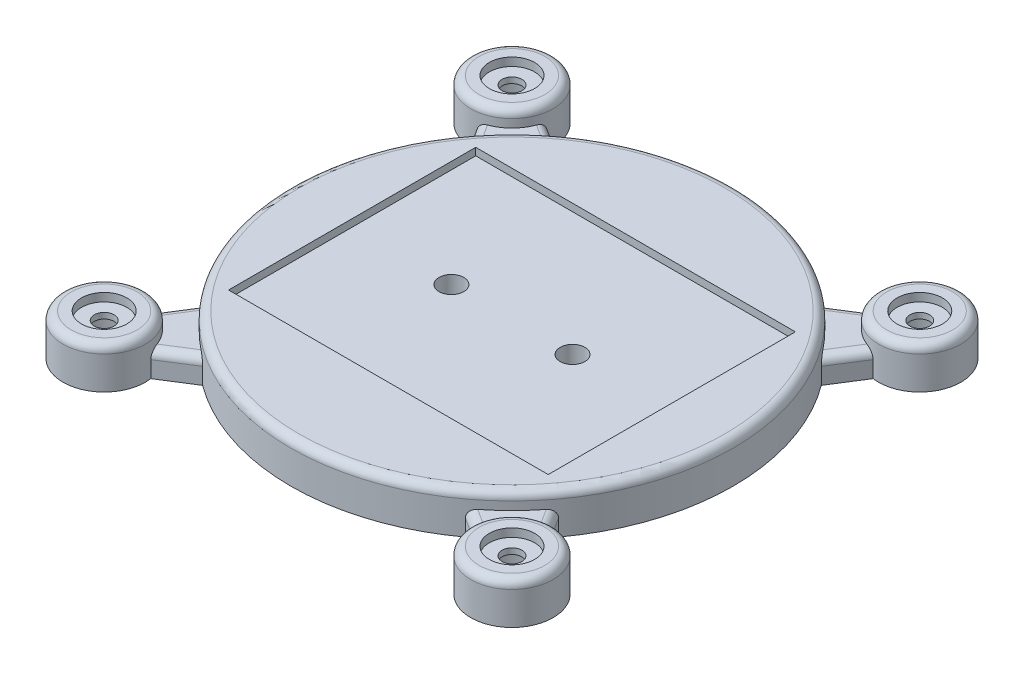
from build123d import *

# Parameters (mm, degrees)
SKETCH1_R                 = 26.85
BOSS_EXTRUDE1_DEPTH       = 5
FILLET1_R                 = 1
SKETCH2_W                 = 38.8
SKETCH2_H                 = 30
CUT_EXTRUDE1_DEPTH        = 0.9
SKETCH3_R                 = 1.5
CUT_EXTRUDE2_DEPTH        = 5.1
SKETCH5_R                 = 5
BOSS_EXTRUDE4_DEPTH       = 5
BOSS_EXTRUDE4_2_DEPTH     = 5
BOSS_EXTRUDE4_3_DEPTH     = 5
BOSS_EXTRUDE4_4_DEPTH     = 5
BOSS_EXTRUDE5_DEPTH       = 3
FILLET5_R                 = 1
CIRPATTERN20_COUNT        = 4
FILLET5_OF_CIRPATTERN20_R = 1
FILLET6_R                 = 1
FILLET7_R                 = 1
FILLET8_R                 = 1
FILLET9_R                 = 1
SKETCH9_R                 = 2.75
CUT_EXTRUDE5_DEPTH        = 1
SKETCH10_R                = 1.2
CUT_EXTRUDE6_DEPTH        = 5.0000001
SKETCH11_R                = 3.75
CUT_EXTRUDE7_DEPTH        = 3.3


with BuildPart() as part:
    # Sketch1 → Boss-Extrude1 (new body)
    with BuildSketch(Plane(origin=(0, 0, 0), x_dir=(1, 0, 0), z_dir=(0, 1, 0))):
        Circle(SKETCH1_R)
    extrude(amount=BOSS_EXTRUDE1_DEPTH)

    # Fillet1
    fillet1_edges = [part.edges().sort_by_distance(p)[0] for p in [
        (-26.85, 5, 0),
    ]]
    fillet(fillet1_edges, radius=FILLET1_R)

    # Sketch2 → Cut-Extrude1 (cut)
    with BuildSketch(Plane(origin=(0, 5, 0), x_dir=(1, 0, 0), z_dir=(0, 1, 0))):
        Rectangle(SKETCH2_W, SKETCH2_H)
    extrude(amount=-CUT_EXTRUDE1_DEPTH, mode=Mode.SUBTRACT)

    # Sketch3 → Cut-Extrude2 (cut, through all)
    with BuildSketch(Plane(origin=(0, 4.1, 0), x_dir=(1, 0, 0), z_dir=(0, 1, 0))):
        with Locations((7.35, 0)):
            Circle(SKETCH3_R)
        with Locations((-7.35, 0)):
            Circle(SKETCH3_R)
    extrude(amount=-CUT_EXTRUDE2_DEPTH, mode=Mode.SUBTRACT)



with BuildPart() as body_2:
    # Sketch5 → Boss-Extrude4 (new body)
    with BuildSketch(Plane(origin=(0, 0, 0), x_dir=(1, 0, 0), z_dir=(0, 1, 0))):
        with Locations((24.748737342, -24.748737342)):
            Circle(SKETCH5_R)
    extrude(amount=BOSS_EXTRUDE4_DEPTH)


with BuildPart() as body_3:
    # Sketch5 → Boss-Extrude4 2 (new body)
    with BuildSketch(Plane(origin=(0, 0, 0), x_dir=(1, 0, 0), z_dir=(0, 1, 0))):
        with Locations((-24.748737342, -24.748737342)):
            Circle(SKETCH5_R)
    extrude(amount=BOSS_EXTRUDE4_2_DEPTH)

    # Fillet8
    fillet8_edges = [body_3.edges().sort_by_distance(p)[0] for p in [
        (-29.748737342, 5, 24.748737342),
    ]]
    fillet(fillet8_edges, radius=FILLET8_R)


with BuildPart() as body_4:
    # Sketch5 → Boss-Extrude4 3 (new body)
    with BuildSketch(Plane(origin=(0, 0, 0), x_dir=(1, 0, 0), z_dir=(0, 1, 0))):
        with Locations((-24.748737342, 24.748737342)):
            Circle(SKETCH5_R)
    extrude(amount=BOSS_EXTRUDE4_3_DEPTH)

    # Fillet6
    fillet6_edges = [body_4.edges().sort_by_distance(p)[0] for p in [
        (-29.748737342, 5, -24.748737342),
    ]]
    fillet(fillet6_edges, radius=FILLET6_R)


with BuildPart() as body_5:
    # Sketch5 → Boss-Extrude4 4 (new body)
    with BuildSketch(Plane(origin=(0, 0, 0), x_dir=(1, 0, 0), z_dir=(0, 1, 0))):
        with Locations((24.748737342, 24.748737342)):
            Circle(SKETCH5_R)
    extrude(amount=BOSS_EXTRUDE4_4_DEPTH)

    # Fillet7
    fillet7_edges = [body_5.edges().sort_by_distance(p)[0] for p in [
        (19.748737342, 5, -24.748737342),
    ]]
    fillet(fillet7_edges, radius=FILLET7_R)


with BuildPart() as part_1:
    add(part.part)

    add(body_2.part)  # Boss-Extrude5 merges body 2
    # Sketch6 → Boss-Extrude5 (add)
    with BuildSketch(Plane(origin=(0, 0, 0), x_dir=(1, 0, 0), z_dir=(0, 1, 0))):
        with BuildLine():
            Line((24.04163056, -19.798989873), (21.602378494, -15.945524244))
            ThreePointArc((21.602378494, -15.945524244), (18.985817075, -18.985817075), (15.945524244, -21.602378494))
            Line((15.945524244, -21.602378494), (19.798989873, -24.04163056))
            ThreePointArc((19.798989873, -24.04163056), (21.213203436, -21.213203436), (24.04163056, -19.798989873))
        make_face()
    boss_extrude5 = extrude(amount=BOSS_EXTRUDE5_DEPTH)

    # Fillet5
    fillet5_edges = [part_1.edges().sort_by_distance(p)[0] for p in [
        (17.872257059, 3, 22.822004527),
        (22.822004527, 3, 17.872257059),
    ]]
    fillet(fillet5_edges, radius=FILLET5_R)

    # CirPattern20: Boss-Extrude5 ×4 about axis
    cirpattern20_axis = Axis((0, 0, 0), (0, 1, 0))
    for i in range(1, CIRPATTERN20_COUNT):
        add(boss_extrude5.rotate(cirpattern20_axis, i * 360 / CIRPATTERN20_COUNT))

    # Fillet5 of CirPattern20
    fillet5_of_cirpattern20_edges = [part_1.edges().sort_by_distance(p)[0] for p in [
        (22.822004527, 3, -17.872257059),
        (17.872257059, 3, -22.822004527),
        (-17.872257059, 3, -22.822004527),
        (-22.822004527, 3, -17.872257059),
        (-22.822004527, 3, 17.872257059),
        (-17.872257059, 3, 22.822004527),
    ]]
    fillet(fillet5_of_cirpattern20_edges, radius=FILLET5_OF_CIRPATTERN20_R)

    # Fillet9
    fillet9_edges = [part_1.edges().sort_by_distance(p)[0] for p in [
        (19.748737342, 5, 24.748737342),
    ]]
    fillet(fillet9_edges, radius=FILLET9_R)


with BuildPart() as cut_extrude5_tool:
    # Sketch9 → Cut-Extrude5 (new body)
    with BuildSketch(Plane(origin=(0, 5, 0), x_dir=(1, 0, 0), z_dir=(0, 1, 0))):
        with Locations((24.748737342, -24.748737342)):
            Circle(SKETCH9_R)
        with Locations((-24.748737342, -24.748737342)):
            Circle(SKETCH9_R)
        with Locations((-24.748737342, 24.748737342)):
            Circle(SKETCH9_R)
        with Locations((24.748737342, 24.748737342)):
            Circle(SKETCH9_R)
    extrude(amount=-CUT_EXTRUDE5_DEPTH)


with BuildPart() as part_2:
    add(part_1.part)

    # Cut-Extrude5: cut by cut_extrude5_tool
    add(cut_extrude5_tool.part, mode=Mode.SUBTRACT)


with BuildPart() as body_3_1:
    add(body_3.part)

    # Cut-Extrude5: cut by cut_extrude5_tool
    add(cut_extrude5_tool.part, mode=Mode.SUBTRACT)


with BuildPart() as body_4_1:
    add(body_4.part)

    # Cut-Extrude5: cut by cut_extrude5_tool
    add(cut_extrude5_tool.part, mode=Mode.SUBTRACT)


with BuildPart() as body_5_1:
    add(body_5.part)

    # Cut-Extrude5: cut by cut_extrude5_tool
    add(cut_extrude5_tool.part, mode=Mode.SUBTRACT)


with BuildPart() as cut_extrude6_tool:
    # Sketch10 → Cut-Extrude6 (new body, through all)
    with BuildSketch(Plane(origin=(0, 4, 0), x_dir=(1, 0, 0), z_dir=(0, 1, 0))):
        with Locations((24.748737342, -24.748737342)):
            Circle(SKETCH10_R)
        with Locations((-24.748737342, -24.748737342)):
            Circle(SKETCH10_R)
        with Locations((-24.748737342, 24.748737342)):
            Circle(SKETCH10_R)
        with Locations((24.748737342, 24.748737342)):
            Circle(SKETCH10_R)
    extrude(amount=-CUT_EXTRUDE6_DEPTH)


with BuildPart() as part_3:
    add(part_2.part)

    # Cut-Extrude6: cut by cut_extrude6_tool
    add(cut_extrude6_tool.part, mode=Mode.SUBTRACT)


with BuildPart() as body_3_2:
    add(body_3_1.part)

    # Cut-Extrude6: cut by cut_extrude6_tool
    add(cut_extrude6_tool.part, mode=Mode.SUBTRACT)


with BuildPart() as body_4_2:
    add(body_4_1.part)

    # Cut-Extrude6: cut by cut_extrude6_tool
    add(cut_extrude6_tool.part, mode=Mode.SUBTRACT)


with BuildPart() as body_5_2:
    add(body_5_1.part)

    # Cut-Extrude6: cut by cut_extrude6_tool
    add(cut_extrude6_tool.part, mode=Mode.SUBTRACT)


with BuildPart() as cut_extrude7_tool:
    # Sketch11 → Cut-Extrude7 (new body)
    with BuildSketch(Plane.XZ):
        with Locations((24.748737342, 24.748737342)):
            Circle(SKETCH11_R)
        with Locations((24.748737342, -24.748737342)):
            Circle(SKETCH11_R)
        with Locations((-24.748737342, -24.748737342)):
            Circle(SKETCH11_R)
        with Locations((-24.748737342, 24.748737342)):
            Circle(SKETCH11_R)
    extrude(amount=-CUT_EXTRUDE7_DEPTH)


with BuildPart() as part_4:
    add(part_3.part)

    # Cut-Extrude7: cut by cut_extrude7_tool
    add(cut_extrude7_tool.part, mode=Mode.SUBTRACT)


with BuildPart() as body_3_3:
    add(body_3_2.part)

    # Cut-Extrude7: cut by cut_extrude7_tool
    add(cut_extrude7_tool.part, mode=Mode.SUBTRACT)


with BuildPart() as body_4_3:
    add(body_4_2.part)

    # Cut-Extrude7: cut by cut_extrude7_tool
    add(cut_extrude7_tool.part, mode=Mode.SUBTRACT)


with BuildPart() as body_5_3:
    add(body_5_2.part)

    # Cut-Extrude7: cut by cut_extrude7_tool
    add(cut_extrude7_tool.part, mode=Mode.SUBTRACT)


solid = Compound([part_4.part, body_3_3.part, body_4_3.part, body_5_3.part])
